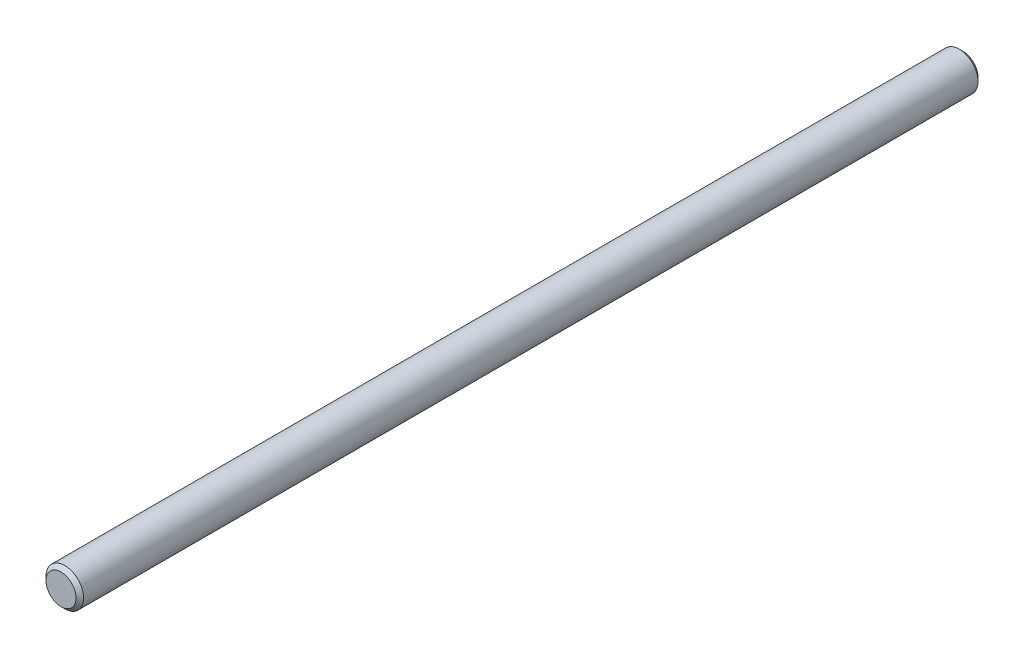
from build123d import *

# Parameters (mm, degrees)
SKETCH3_R           = 3.175
BOSS_EXTRUDE1_DEPTH = 76.2
CHAMFER1_SIZE       = 0.635


with BuildPart() as part:
    # Sketch3 → Boss-Extrude1 (new body, symmetric)
    with BuildSketch(Plane.XY):
        Circle(SKETCH3_R)
    extrude(amount=BOSS_EXTRUDE1_DEPTH, both=True)

    # Chamfer1
    chamfer1_edges = [part.edges().sort_by_distance(p)[0] for p in [
        (-3.175, 0, -76.2),
        (-3.175, 0, 76.2),
    ]]
    chamfer(chamfer1_edges, length=CHAMFER1_SIZE)


solid = part.part
